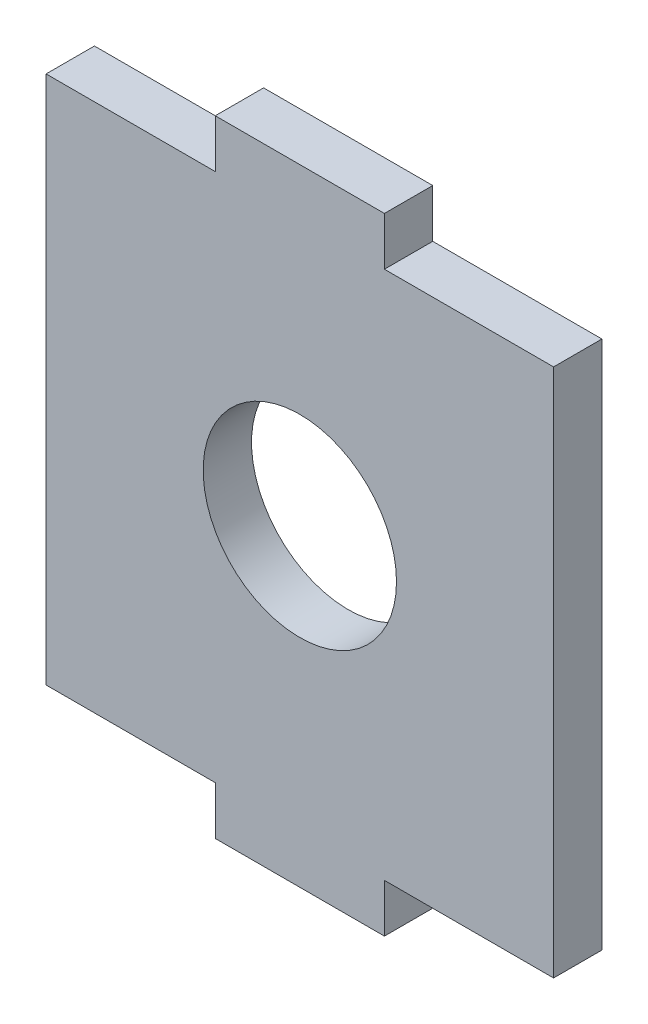
from build123d import *

# Parameters (mm, degrees)
SKETCH1_R           = 4
BOSS_EXTRUDE1_DEPTH = 2


with BuildPart() as part:
    # Sketch1 → Boss-Extrude1 (new body)
    with BuildSketch(Plane.XY):
        Polygon((3.5, 10.95), (10.5, 10.95), (10.5, -10.95), (3.5, -10.95), (3.5, -12.95), (-3.5, -12.95), (-3.5, -10.95), (-10.5, -10.95), (-10.5, 10.95), (-3.5, 10.95), (-3.5, 12.95), (3.5, 12.95), align=None)
        Circle(SKETCH1_R, mode=Mode.SUBTRACT)
    extrude(amount=BOSS_EXTRUDE1_DEPTH)


solid = part.part
